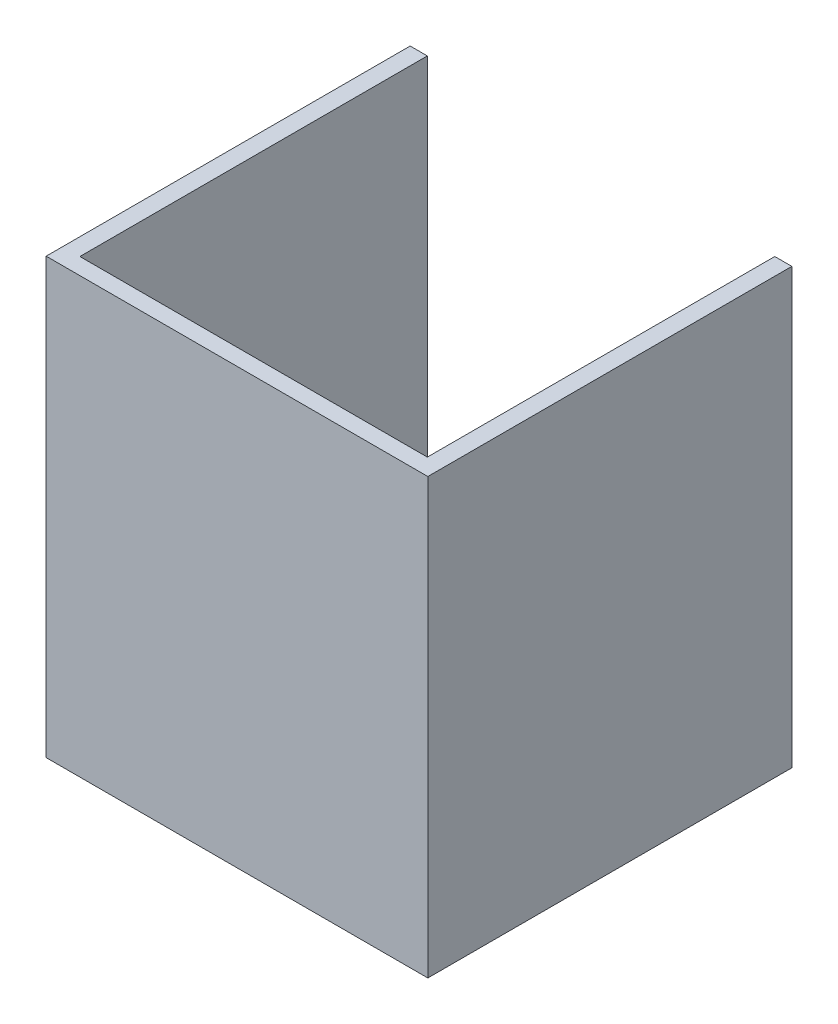
from build123d import *

# Parameters (mm, degrees)
SALIENTE_EXTRUIR1_DEPTH = 63.5


with BuildPart() as part:
    # Croquis1 → Saliente-Extruir1 (new body)
    with BuildSketch(Plane(origin=(0, 0, 0), x_dir=(1, 0, 0), z_dir=(0, 1, 0))):
        Polygon((0, 0), (0, -50.8), (-50.8, -50.8), (-50.8, 0), (-53.309981872, 0), (-53.309981872, -53.221954633), (2.493393923, -53.221954633), (2.493393923, 0), align=None)
    extrude(amount=SALIENTE_EXTRUIR1_DEPTH)


solid = part.part
